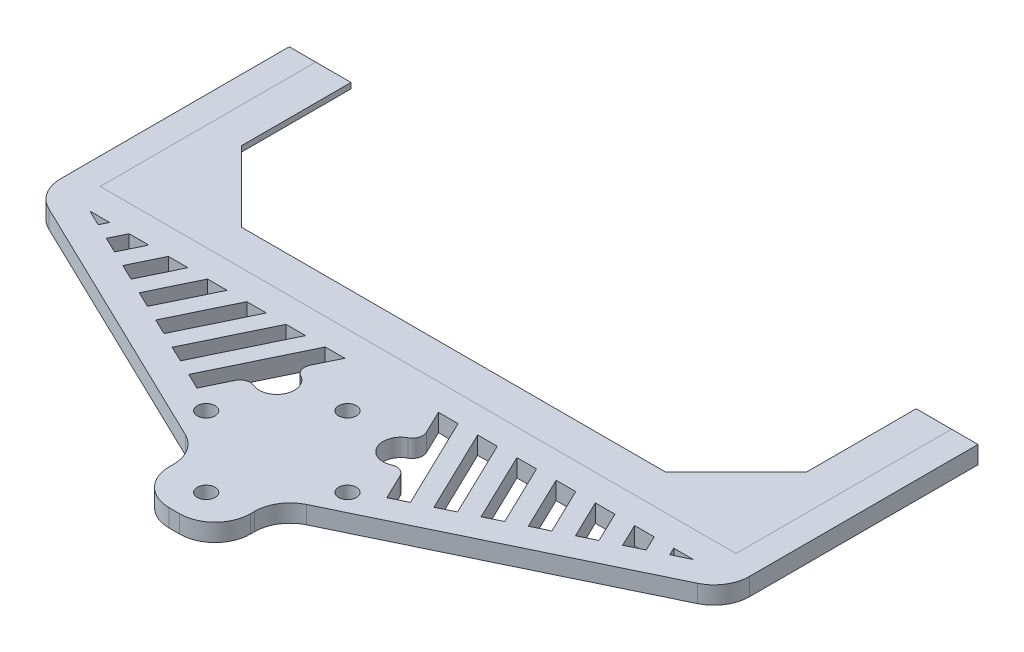
from build123d import *

# Parameters (mm, degrees)
BOSS_EXTRUDE1_DEPTH  = 6.35
M6_CLEARANCE_HOLE1_D = 6.4
CUT_EXTRUDE1_DEPTH   = 7.35
BOSS_EXTRUDE2_DEPTH  = 2


with BuildPart() as part:
    # Sketch1 → Boss-Extrude1 (new body)
    with BuildSketch(Plane(origin=(0, 0, 0), x_dir=(1, 0, 0), z_dir=(0, 1, 0))):
        with BuildLine():
            Line((-114.3, 128.27), (-114.3, 50.8))
            Line((-114.3, 50.8), (114.3, 50.8))
            Line((114.3, 50.8), (114.3, 128.27))
            Line((114.3, 128.27), (123.825, 128.27))
            Line((123.825, 128.27), (123.825, 46.072872191))
            ThreePointArc((123.825, 46.072872191), (121.881092646, 39.32035629), (116.644453387, 34.634968786))
            Line((116.644453387, 34.634968786), (21.785546613, -11.139968786))
            ThreePointArc((21.785546613, -11.139968786), (16.548907354, -15.82535629), (14.605, -22.577872191))
            Line((14.605, -22.577872191), (14.605, -24.13))
            ThreePointArc((14.605, -24.13), (10.885256121, -33.110256121), (1.905, -36.83))
            Line((1.905, -36.83), (-1.905, -36.83))
            ThreePointArc((-1.905, -36.83), (-10.885256121, -33.110256121), (-14.605, -24.13))
            Line((-14.605, -24.13), (-14.605, -22.577872191))
            ThreePointArc((-14.605, -22.577872191), (-16.548907354, -15.82535629), (-21.785546613, -11.139968786))
            Line((-21.785546613, -11.139968786), (-116.644453387, 34.634968786))
            ThreePointArc((-116.644453387, 34.634968786), (-121.881092646, 39.32035629), (-123.825, 46.072872191))
            Line((-123.825, 46.072872191), (-123.825, 128.27))
            Line((-123.825, 128.27), (-114.3, 128.27))
        make_face()
    extrude(amount=BOSS_EXTRUDE1_DEPTH)

    # M6 Clearance Hole1 (through all)
    with Locations(Plane(origin=(0, 0, 0), x_dir=(-1, 0, 0), z_dir=(0, -1, 0))):
        with Locations((0, 25.4), (0, -25.4), (-25.4, 0), (25.4, 0)):
            Hole(M6_CLEARANCE_HOLE1_D / 2)

    # Sketch7 → Cut-Extrude1 (cut, through all)
    with BuildSketch(Plane(origin=(0, 6.35, 0), x_dir=(1, 0, 0), z_dir=(0, 1, 0))):
        Polygon((-62.736332011, 19.197186451), (-52.082503379, 41.275), (-45.031823098, 41.275), (-57.017380308, 16.437459757), align=None)
        Polygon((-108.487945631, 41.275), (-101.43726535, 41.275), (-102.768993928, 38.515273306), align=None)
        Polygon((-97.050042226, 35.755546613), (-94.386585068, 41.275), (-87.335904787, 41.275), (-91.331090523, 32.995819919), align=None)
        Polygon((-80.285224505, 41.275), (-73.234544224, 41.275), (-79.893187118, 27.476366532), (-85.612138821, 30.236093225), align=None)
        Polygon((-74.174235416, 24.716639838), (-66.183863942, 41.275), (-59.133183661, 41.275), (-68.455283713, 21.956913144), align=None)
        Polygon((-51.298428605, 13.677733063), (-37.981142816, 41.275), (-30.930462535, 41.275), (-45.579476903, 10.91800637), align=None)
        with BuildLine():
            Line((-39.8605252, 8.158279676), (-23.879782253, 41.275))
            Line((-23.879782253, 41.275), (-16.829101972, 41.275))
            Line((-16.829101972, 41.275), (-20.883675601, 32.872751034))
            ThreePointArc((-20.883675601, 32.872751034), (-21.07676276, 30.042435177), (-19.260389215, 27.863270739))
            ThreePointArc((-19.260389215, 27.863270739), (-16.554911905, 19.514136914), (-24.774287238, 16.436879654))
            ThreePointArc((-24.774287238, 16.436879654), (-27.61041535, 16.50281776), (-29.705912438, 14.590525299))
            Line((-29.705912438, 14.590525299), (-34.141573498, 5.398552982))
            Line((-34.141573498, 5.398552982), (-39.8605252, 8.158279676))
        make_face()
    cut_extrude1 = extrude(amount=-CUT_EXTRUDE1_DEPTH, mode=Mode.SUBTRACT)

    # Mirror1: Cut-Extrude1 across plane
    add(cut_extrude1.mirror(Plane(origin=(0, 0, 0), x_dir=(0, 0, 1), z_dir=(1, 0, 0))), mode=Mode.SUBTRACT)


with BuildPart() as body_2:
    # Sketch8 → Boss-Extrude2 (new body)
    with BuildSketch(Plane(origin=(0, 6.35, 0), x_dir=(1, 0, 0), z_dir=(0, 1, 0))):
        Polygon((114.3, 128.27), (101.6, 128.27), (101.6, 88.9), (76.2, 63.5), (-76.2, 63.5), (-101.6, 88.9), (-101.6, 128.27), (-114.3, 128.27), (-114.3, 50.8), (114.3, 50.8), align=None)
    extrude(amount=-BOSS_EXTRUDE2_DEPTH)


solid = Compound([part.part, body_2.part])
